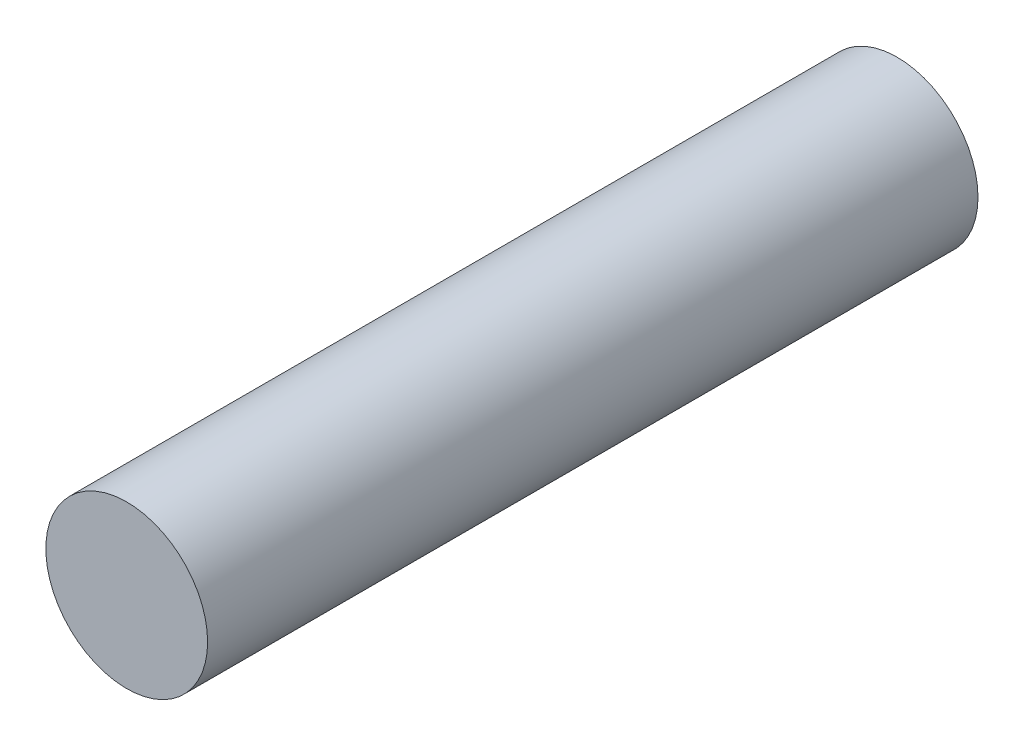
from build123d import *

# Parameters (mm, degrees)
SKETCH1_R           = 1.05
BOSS_EXTRUDE1_DEPTH = 10


with BuildPart() as part:
    # Sketch1 → Boss-Extrude1 (new body)
    with BuildSketch(Plane.XY):
        Circle(SKETCH1_R)
    extrude(amount=BOSS_EXTRUDE1_DEPTH)


solid = part.part
